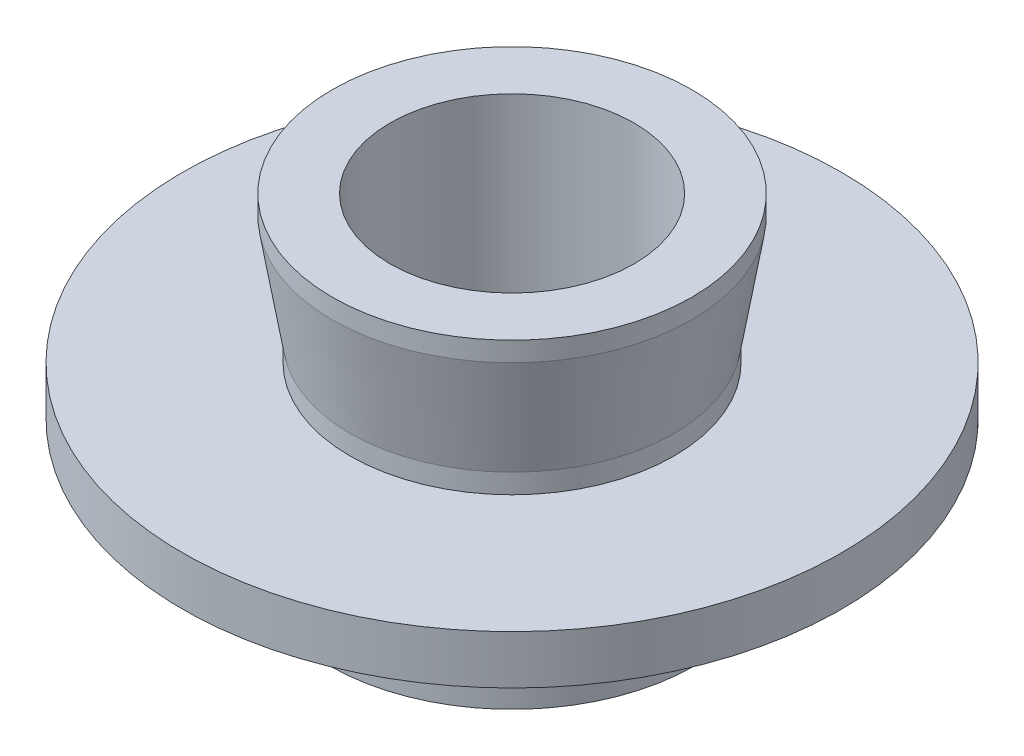
from build123d import *


with BuildPart() as part:
    # 草图1 → 旋转1 (revolve)
    with BuildSketch(Plane.XY, mode=Mode.PRIVATE) as revolve_1_sk:
        Polygon((-5, 0), (-5, 13), (-7.365, 13), (-7.365, 12.2), (-6.635, 7.8), (-6.635, 7), (-13.5, 7), (-13.5, 5), (-7.1, 5), (-7.1, 4), (-7.5, 4), (-7.5, 0), align=None)
    revolve(revolve_1_sk.sketch.rotate(Axis((0, 0, 0), (0, 1, 0)), 270), axis=Axis((0, 0, 0), (0, 1, 0)))  # turned: the seam where the file's is


solid = part.part
